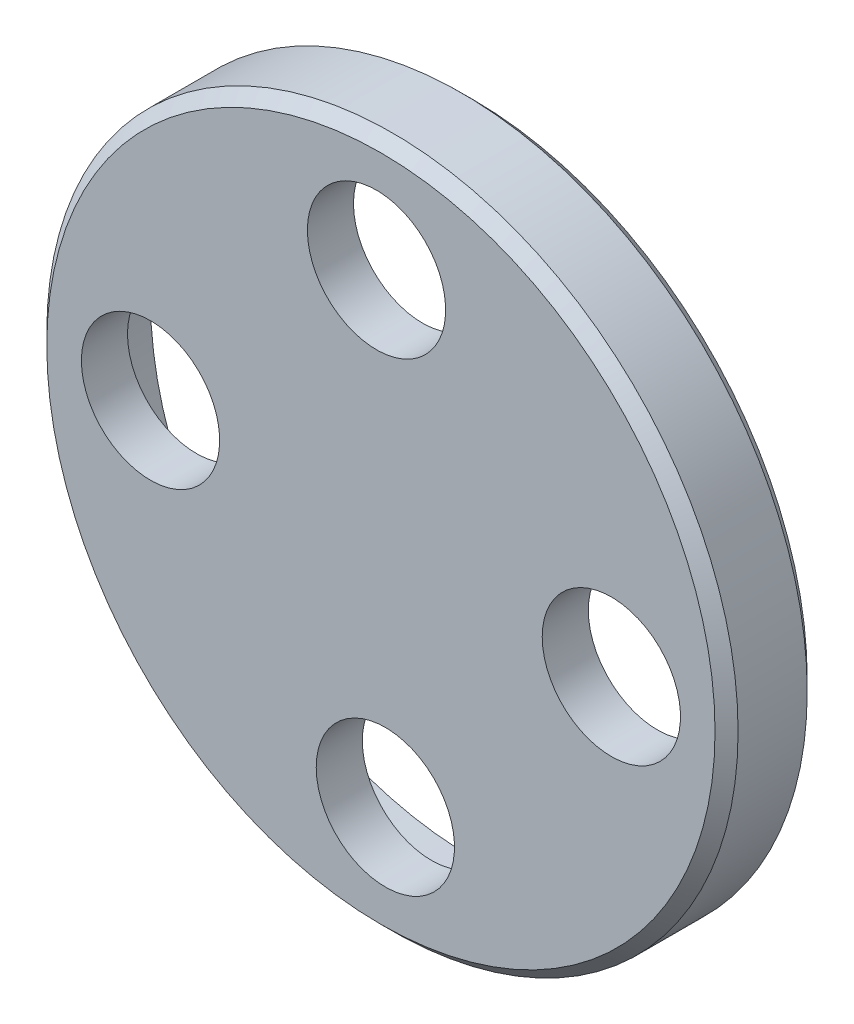
from build123d import *

# Parameters (mm, degrees)
SKETCH_1_R          = 15
EXTRUDE_1_DEPTH     = 4
SKETCH_3_R          = 14
CUT_EXTRUDE_2_DEPTH = 2
SKETCH_5_R          = 3
CUT_EXTRUDE_3_DEPTH = 3
CHAMFER_1_SIZE      = 0.5
CHAMFER_3_SIZE      = 0.5


with BuildPart() as part:
    # Эскиз1 → Вытянуть1 (new body)
    with BuildSketch(Plane.XY):
        Circle(SKETCH_1_R)
    extrude(amount=EXTRUDE_1_DEPTH)

    # Эскиз3 → Вытянуть2 (cut)
    with BuildSketch(Plane(origin=(0, 0, 0), x_dir=(-1, 0, 0), z_dir=(0, 0, -1))):
        Circle(SKETCH_3_R)
    extrude(amount=-CUT_EXTRUDE_2_DEPTH, mode=Mode.SUBTRACT)

    # Эскиз5 → Вытянуть3 (cut, through all)
    with BuildSketch(Plane(origin=(0, 0, 2), x_dir=(-1, 0, 0), z_dir=(0, 0, -1))):
        with Locations((9.998142701, 0.192724)):
            Circle(SKETCH_5_R)
        with Locations((-0.192724, -9.998142701)):
            Circle(SKETCH_5_R)
        with Locations((0.1908667, 10)):
            Circle(SKETCH_5_R)
        with Locations((-10, -0.1908667)):
            Circle(SKETCH_5_R)
    extrude(amount=-CUT_EXTRUDE_3_DEPTH, mode=Mode.SUBTRACT)

    # Фаска1
    chamfer_1_edges = [part.edges().sort_by_distance(p)[0] for p in [
        (-15, 0, 4),
    ]]
    chamfer(chamfer_1_edges, length=CHAMFER_1_SIZE)

    # Фаска3
    chamfer_3_edges = [part.edges().sort_by_distance(p)[0] for p in [
        (-15, 0, 0),
    ]]
    chamfer(chamfer_3_edges, length=CHAMFER_3_SIZE)


solid = part.part
